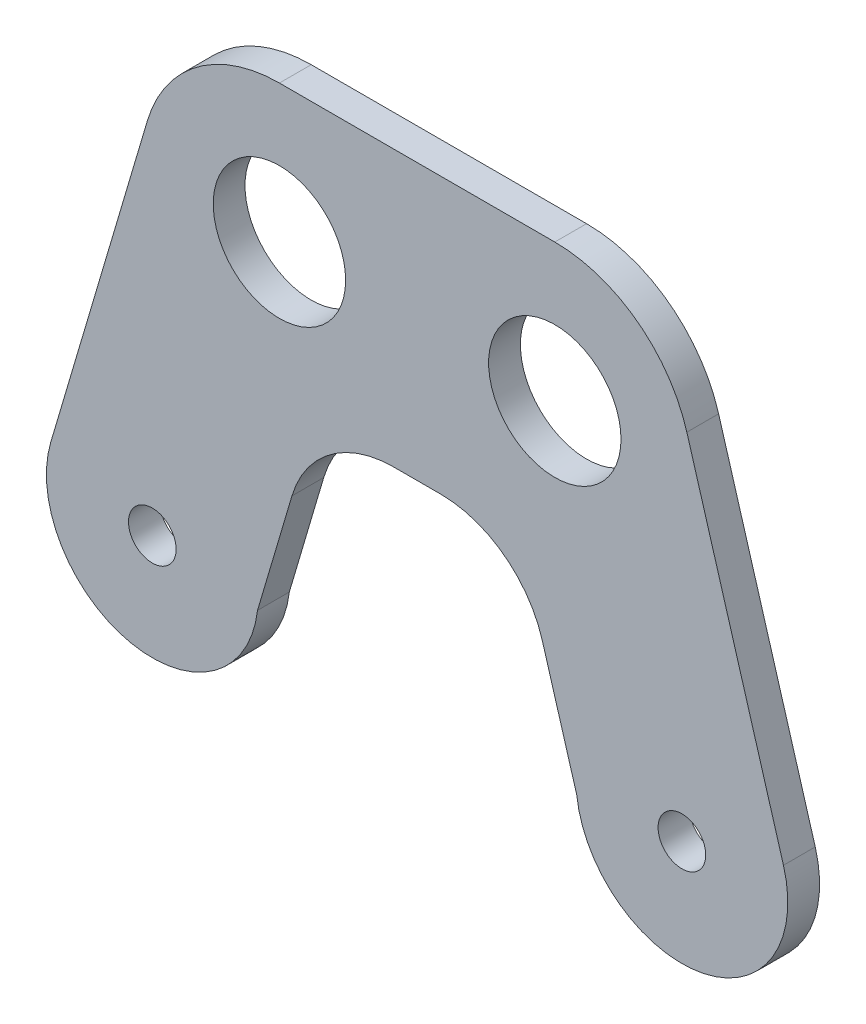
from build123d import *

# Parameters (mm, degrees)
ESQUISSE1_R          = 10
ESQUISSE1_R_2        = 2.25
BOSS_EXTRU_1_DEPTH   = 3
BOSS_EXTRU_1_2_DEPTH = 3
ESQUISSE1_R_3        = 6.25
BOSS_EXTRU_1_3_DEPTH = 3
BOSS_EXTRU_2_DEPTH   = 3
CONG_1_R             = 10


with BuildPart() as part:
    # Esquisse1 → Boss.-Extru.1 (new body)
    with BuildSketch(Plane.XY):
        Circle(ESQUISSE1_R)
        Circle(ESQUISSE1_R_2, mode=Mode.SUBTRACT)
    extrude(amount=BOSS_EXTRU_1_DEPTH)



with BuildPart() as body_2:
    # Esquisse1 → Boss.-Extru.1 2 (new body)
    with BuildSketch(Plane.XY):
        with Locations((50, 0)):
            Circle(ESQUISSE1_R)
        with Locations((50, 0)):
            Circle(ESQUISSE1_R_2, mode=Mode.SUBTRACT)
    extrude(amount=BOSS_EXTRU_1_2_DEPTH)


with BuildPart() as body_3:
    # Esquisse1 → Boss.-Extru.1 3 (new body)
    with BuildSketch(Plane.XY):
        with BuildLine():
            Line((12, 43), (38, 43))
            ThreePointArc((38, 43), (51, 30), (38, 17))
            Line((38, 17), (12, 17))
            ThreePointArc((12, 17), (-1, 30), (12, 43))
        make_face()
        with Locations((12, 30)):
            Circle(ESQUISSE1_R_3, mode=Mode.SUBTRACT)
        with Locations((38, 30)):
            Circle(ESQUISSE1_R_3, mode=Mode.SUBTRACT)
    extrude(amount=BOSS_EXTRU_1_3_DEPTH)


with BuildPart() as part_1:
    add(part.part)

    add(body_2.part)  # Boss.-Extru.2 merges body 2

    add(body_3.part)  # Boss.-Extru.2 merges body 3
    # Esquisse2 → Boss.-Extru.2 (add)
    with BuildSketch(Plane.XY.offset(3)):
        with BuildLine():
            ThreePointArc((12, 17), (1.585468462, 22.219413078), (-0.46633352, 33.686533408))
            Line((-0.46633352, 33.686533408), (-9.589487323, 2.835794929))
            ThreePointArc((-9.589487323, 2.835794929), (2.00193965, 9.797562842), (9.933272577, -1.153297843))
            Line((9.933272577, -1.153297843), (15.301550175, 17))
            Line((15.301550175, 17), (12, 17))
        make_face()
        with BuildLine():
            Line((38, 17), (34.698449825, 17))
            Line((34.698449825, 17), (40.066727423, -1.153297843))
            ThreePointArc((40.066727423, -1.153297843), (47.99806035, 9.797562842), (59.589487323, 2.835794929))
            Line((59.589487323, 2.835794929), (50.46633352, 33.686533408))
            ThreePointArc((50.46633352, 33.686533408), (48.414531538, 22.219413078), (38, 17))
        make_face()
    extrude(amount=-BOSS_EXTRU_2_DEPTH)

    # Congé1
    cong_1_edges = [part_1.edges().sort_by_distance(p)[0] for p in [
        (15.301550175, 17, 1.5),
        (34.698449825, 17, 1.5),
    ]]
    fillet(cong_1_edges, radius=CONG_1_R)


solid = part_1.part
